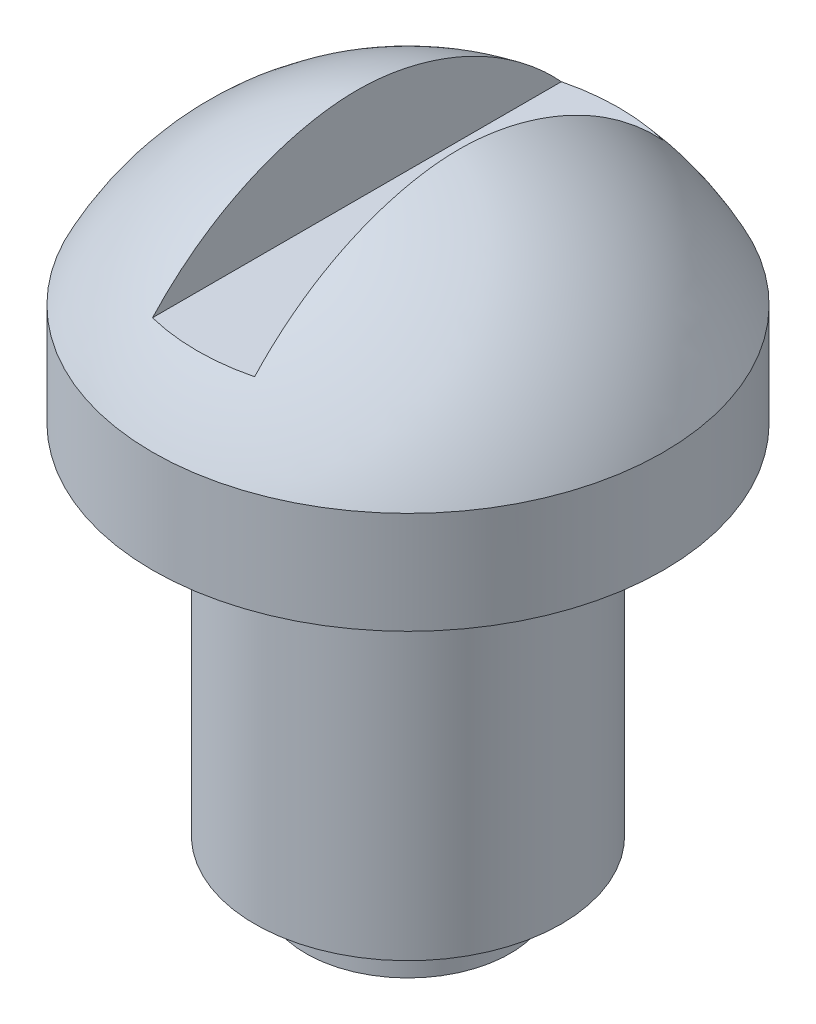
from build123d import *

# Parameters (mm, degrees)
SKETCH2_W               = 2
SKETCH2_H               = 4
CUT_EXTRUDE1_DEPTH      = 6.0000001
CUT_EXTRUDE1_DEPTH_BACK = 6.0000001


with BuildPart() as part:
    # Sketch1 → Revolve1 (revolve)
    with BuildSketch(Plane.XY):
        with BuildLine():
            Line((0, 0), (2, 0))
            Line((2, 0), (2, 1))
            Line((2, 1), (3, 1))
            Line((3, 1), (3, 8))
            Line((3, 8), (5, 8))
            Line((5, 8), (5, 10))
            ThreePointArc((5, 10), (2.938358294, 12.309260763), (0, 13.283479594))
            Line((0, 13.283479594), (0, 0))
        make_face()
    revolve(axis=Axis((0, 13.283479594, 0), (0, -1, 0)))

    # Sketch2 → Cut-Extrude1 (cut, two sides)
    with BuildSketch(Plane.XY) as cut_extrude1_sk:
        with Locations((0, 13.283479594)):
            Rectangle(SKETCH2_W, SKETCH2_H)
    extrude(amount=CUT_EXTRUDE1_DEPTH, mode=Mode.SUBTRACT)
    extrude(cut_extrude1_sk.sketch, amount=-CUT_EXTRUDE1_DEPTH_BACK, mode=Mode.SUBTRACT)


solid = part.part
